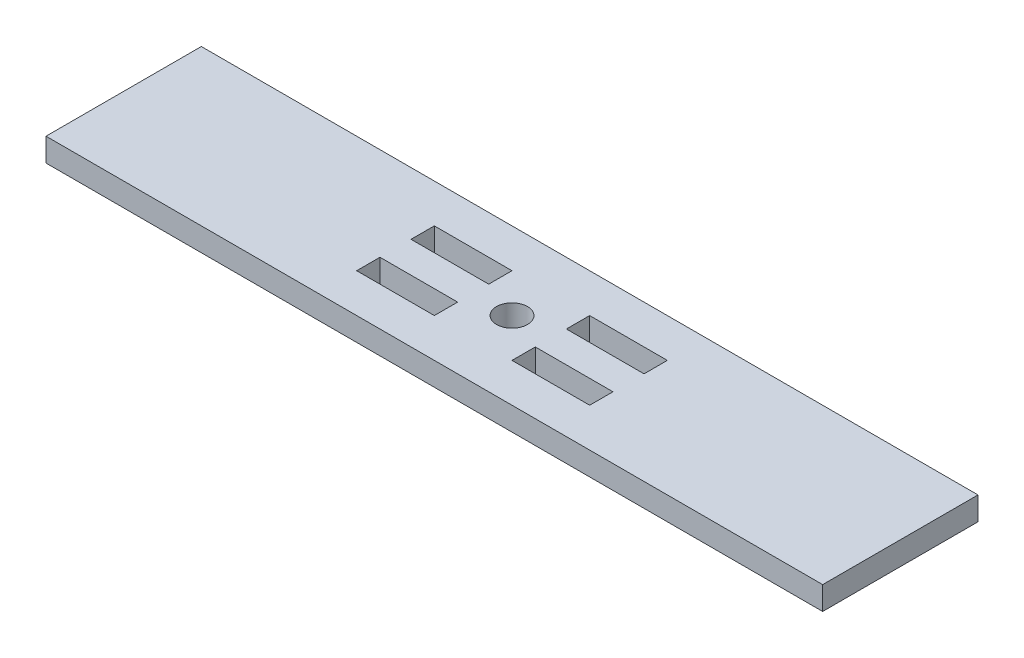
from build123d import *

# Parameters (mm, degrees)
SKETCH1_W           = 50
SKETCH1_H           = 10
BOSS_EXTRUDE1_DEPTH = 1.5
SKETCH3_W           = 5
SKETCH3_H           = 1.5
CUT_EXTRUDE1_DEPTH  = 2
SKETCH2_R           = 1
CUT_EXTRUDE2_DEPTH  = 2


with BuildPart() as part:
    # Sketch1 → Boss-Extrude1 (new body)
    with BuildSketch(Plane(origin=(0, 0, 0), x_dir=(1, 0, 0), z_dir=(0, 1, 0))):
        with Locations((15.170187286, 0.880693734)):
            Rectangle(SKETCH1_W, SKETCH1_H)
    extrude(amount=BOSS_EXTRUDE1_DEPTH)

    # Sketch3 → Cut-Extrude1 (cut)
    with BuildSketch(Plane(origin=(0, 1.5, 0), x_dir=(1, 0, 0), z_dir=(0, 1, 0))):
        with Locations((10.170187286, 2.630693734)):
            Rectangle(SKETCH3_W, SKETCH3_H)
        with Locations((20.170187286, 2.630693734)):
            Rectangle(SKETCH3_W, SKETCH3_H)
        with Locations((20.170187286, -0.869306266)):
            Rectangle(SKETCH3_W, SKETCH3_H)
        with Locations((10.170187286, -0.869306266)):
            Rectangle(SKETCH3_W, SKETCH3_H)
    extrude(amount=-CUT_EXTRUDE1_DEPTH, mode=Mode.SUBTRACT)

    # Sketch2 → Cut-Extrude2 (cut)
    with BuildSketch(Plane(origin=(0, 1.5, 0), x_dir=(1, 0, 0), z_dir=(0, 1, 0))):
        with Locations((15.170187286, 0.880693734)):
            Circle(SKETCH2_R)
    extrude(amount=-CUT_EXTRUDE2_DEPTH, mode=Mode.SUBTRACT)


solid = part.part
